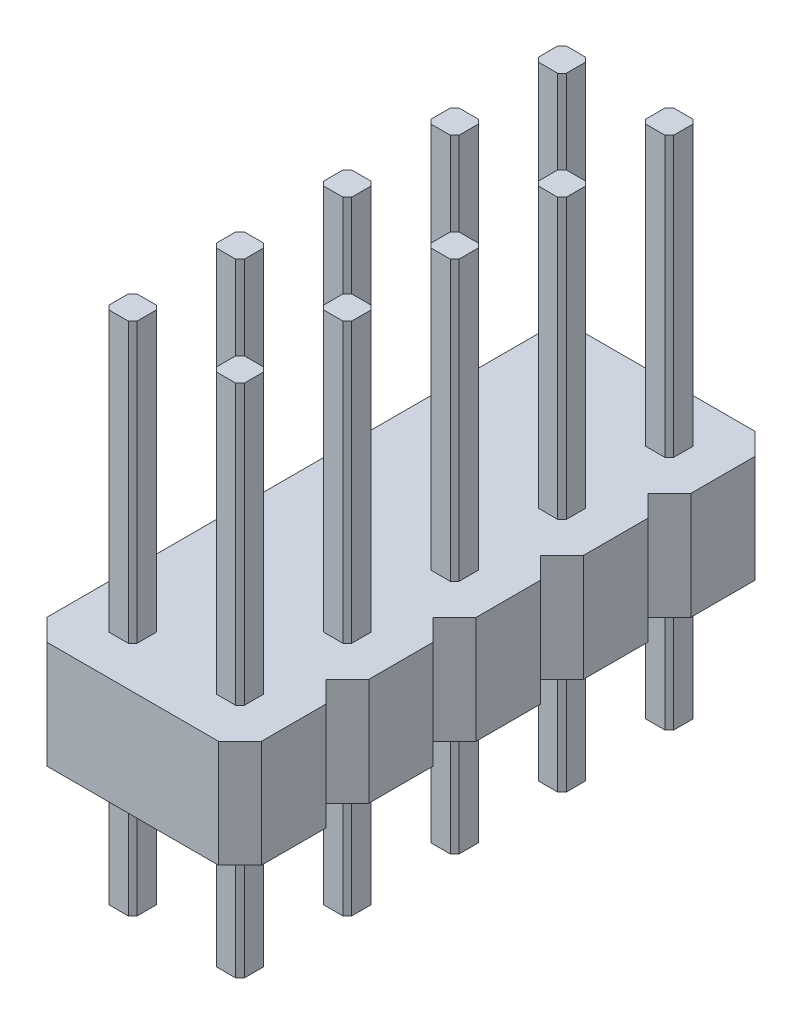
from build123d import *

# Parameters (mm, degrees)
BOSS_EXTRUDE1_DEPTH = 12
LPATTERN1_COUNT     = 2
LPATTERN1_PITCH     = 2.5
BOSS_EXTRUDE3_DEPTH = 2.5
LPATTERN3_COUNT     = 5
LPATTERN3_PITCH     = 2.5


with BuildPart() as part:
    # Sketch1 → Boss-Extrude1 (new body)
    with BuildSketch(Plane(origin=(0, 0, 0), x_dir=(1, 0, 0), z_dir=(0, 1, 0))):
        Polygon((-0.325, 0.225), (-0.225, 0.325), (0.225, 0.325), (0.325, 0.225), (0.325, -0.225), (0.225, -0.325), (-0.225, -0.325), (-0.325, -0.225), align=None)
    extrude(amount=BOSS_EXTRUDE1_DEPTH)


with BuildPart() as lpattern1_1:
    # LPattern1: pattern copy
    add(part.part.moved(Location(Vector(1, 0, 0) * (1 * LPATTERN1_PITCH))))


with BuildPart() as part_1:
    add(part.part)

    add(lpattern1_1.part)  # Boss-Extrude3 merges LPattern1_1
    # Sketch3 → Boss-Extrude3 (add)
    with BuildSketch(Plane(origin=(0, 3, 0), x_dir=(-1, 0, 0), z_dir=(0, -1, 0))):
        Polygon((-3.75, 0.75), (-3.25, 1.25), (0.75, 1.25), (1.25, 0.75), (1.25, -0.75), (0.75, -1.25), (-3.25, -1.25), (-3.75, -0.75), align=None)
    extrude(amount=-BOSS_EXTRUDE3_DEPTH)


with BuildPart() as lpattern3_1:
    # LPattern3: pattern copy
    add(part_1.part.moved(Location(Vector(0, 0, 1) * (1 * LPATTERN3_PITCH))))


with BuildPart() as lpattern3_2:
    # LPattern3: pattern copy
    add(part_1.part.moved(Location(Vector(0, 0, 1) * (2 * LPATTERN3_PITCH))))


with BuildPart() as lpattern3_3:
    # LPattern3: pattern copy
    add(part_1.part.moved(Location(Vector(0, 0, 1) * (3 * LPATTERN3_PITCH))))


with BuildPart() as lpattern3_4:
    # LPattern3: pattern copy
    add(part_1.part.moved(Location(Vector(0, 0, 1) * (4 * LPATTERN3_PITCH))))


with BuildPart() as part_2:
    add(part_1.part)

    # Combine1: union LPattern3_1, LPattern3_2, LPattern3_3, LPattern3_4
    add(lpattern3_1.part)
    add(lpattern3_2.part)
    add(lpattern3_3.part)
    add(lpattern3_4.part)


solid = part_2.part
